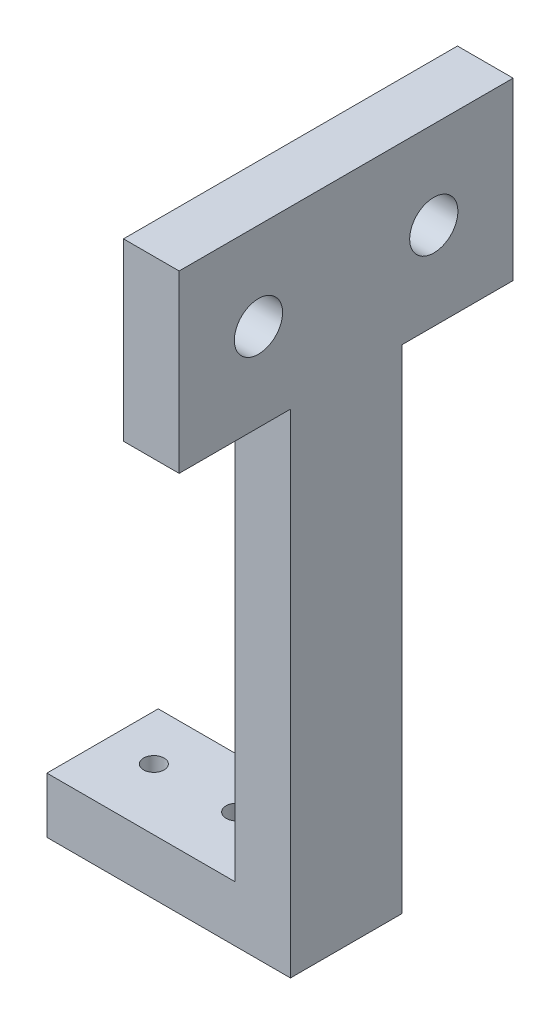
from build123d import *

# Parameters (mm, degrees)
BOSS_EXTRUDE1_DEPTH = 6.35
SKETCH2_W           = 38.1
SKETCH2_H           = 20
BOSS_EXTRUDE2_DEPTH = 6.35
SKETCH3_R           = 1.175
CUT_EXTRUDE1_DEPTH  = 7.35
SKETCH4_R           = 2.75
CUT_EXTRUDE2_DEPTH  = 7.35


with BuildPart() as part:
    # Sketch1 → Boss-Extrude1 (new body, symmetric)
    with BuildSketch(Plane.XY):
        Polygon((-13.893293336, 0), (13.893293336, 0), (13.893293336, 76.2), (7.543293336, 76.2), (7.543293336, 6.35), (-13.893293336, 6.35), align=None)
    extrude(amount=BOSS_EXTRUDE1_DEPTH, both=True)

    # Sketch2 → Boss-Extrude2 (add)
    with BuildSketch(Plane.ZY.offset(-7.543293336)):
        with Locations((0, 66.2)):
            Rectangle(SKETCH2_W, SKETCH2_H)
    extrude(amount=-BOSS_EXTRUDE2_DEPTH)

    # Sketch3 → Cut-Extrude1 (cut, through all)
    with BuildSketch(Plane(origin=(0, 6.35, 0), x_dir=(1, 0, 0), z_dir=(0, 1, 0))):
        with BuildLine():
            ThreePointArc((2.056706664, 0.65), (1.524137822, 1.673617376), (0.380238611, 1.825))
            ThreePointArc((0.380238611, 1.825), (-0.443293336, 0.65), (0.380238611, -0.525))
            ThreePointArc((0.380238611, -0.525), (1.524137822, -0.373617376), (2.056706664, 0.65))
        make_face()
        with Locations((-8.693293336, 0.65)):
            Circle(SKETCH3_R)
    extrude(amount=-CUT_EXTRUDE1_DEPTH, mode=Mode.SUBTRACT)

    # Sketch4 → Cut-Extrude2 (cut, through all)
    with BuildSketch(Plane.ZY.offset(-7.543293336)):
        with Locations((-10, 66.2)):
            Circle(SKETCH4_R)
        with Locations((10, 66.2)):
            Circle(SKETCH4_R)
    extrude(amount=-CUT_EXTRUDE2_DEPTH, mode=Mode.SUBTRACT)


solid = part.part
